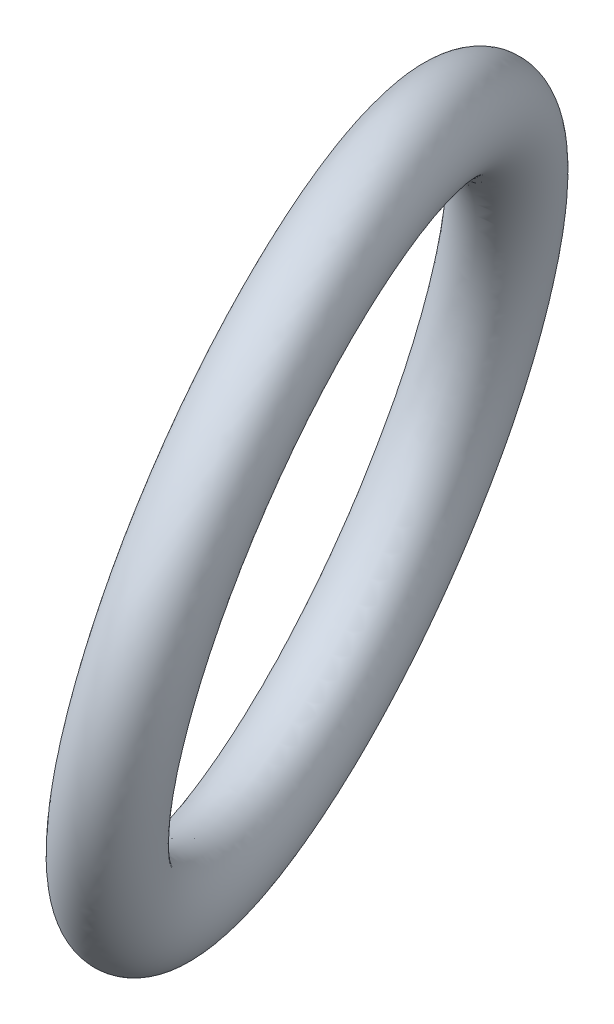
from build123d import *

# Parameters (mm, degrees)
SKETCH8_RX = 35
SKETCH8_RY = 31.26226226


with BuildPart() as part:
    # Sketch8 → Tire design (revolve)
    with BuildSketch(Plane(origin=(0, 258.532768172, -149.263963299), x_dir=(1, 0, 0), z_dir=(0, 0.866025404, -0.5))):
        with Locations(Location((-88.541840407, 210.675148326), (0, 0, 112.795877259))):
            Ellipse(SKETCH8_RX, SKETCH8_RY)
    revolve(axis=Axis((0, 258.532768172, -149.263963299), (0.921891033, -0.193724626, -0.335540895)))


solid = part.part
